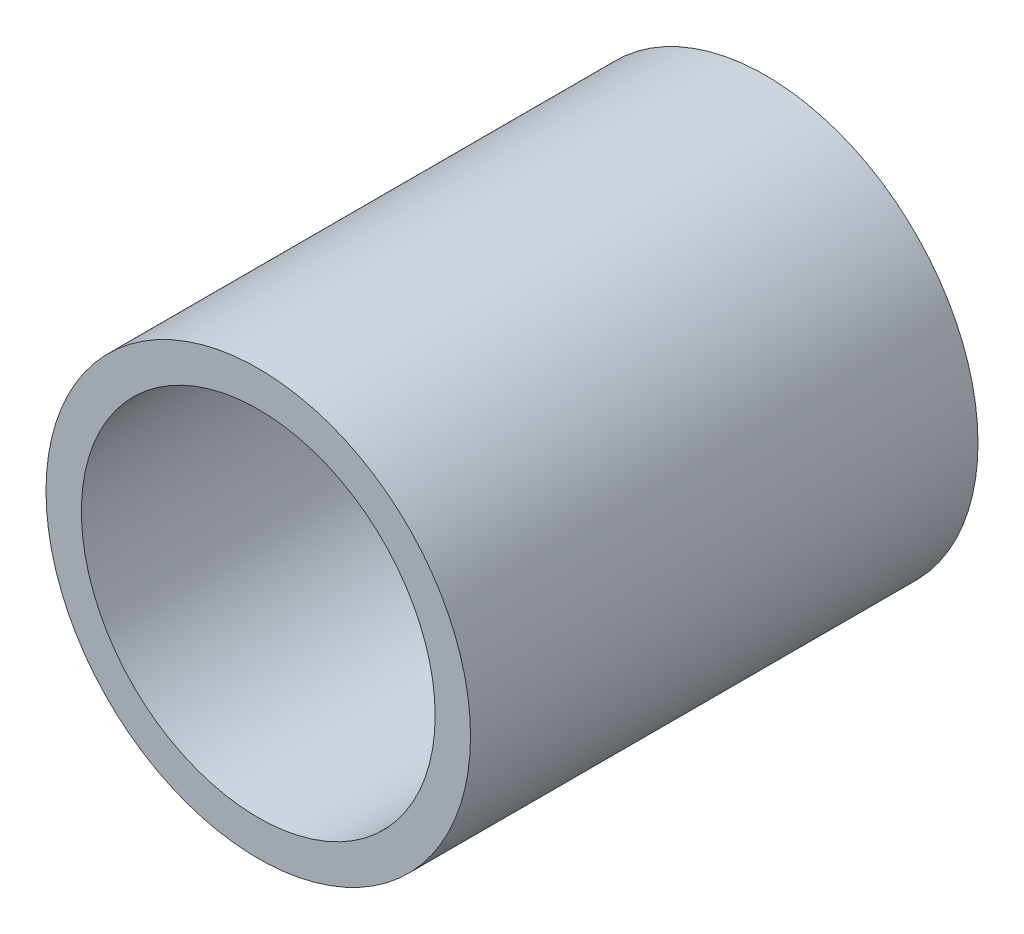
from build123d import *

# Parameters (mm, degrees)
SKETCH1_R           = 6
SKETCH1_R_2         = 5
BOSS_EXTRUDE1_DEPTH = 14.344328


with BuildPart() as part:
    # Sketch1 → Boss-Extrude1 (new body)
    with BuildSketch(Plane.XY):
        Circle(SKETCH1_R)
        Circle(SKETCH1_R_2, mode=Mode.SUBTRACT)
    extrude(amount=BOSS_EXTRUDE1_DEPTH)


solid = part.part
